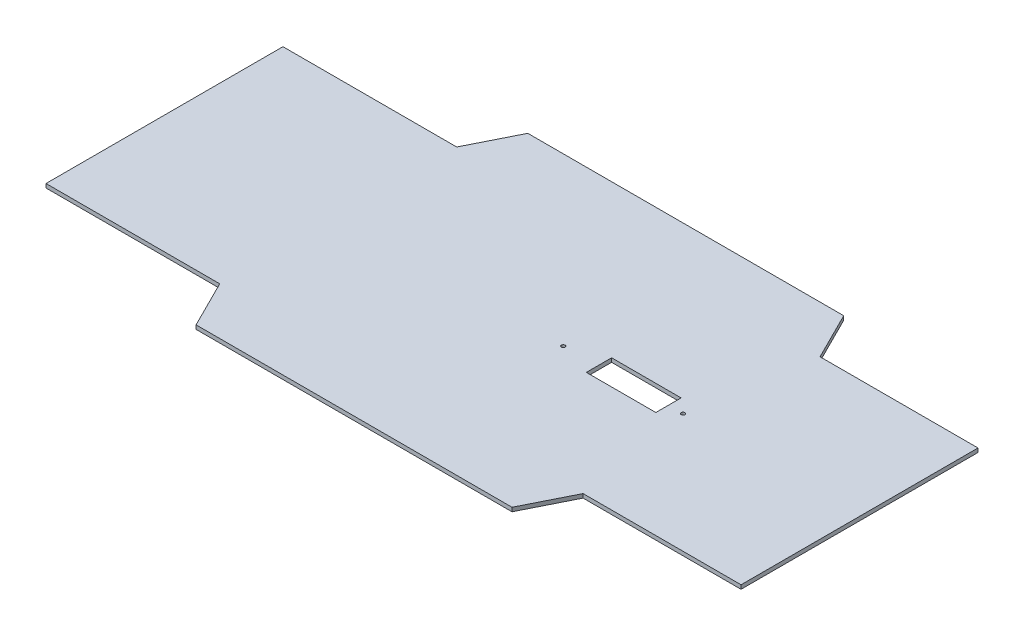
from build123d import *

# Parameters (mm, degrees)
BOSS_EXTRUDE1_DEPTH = 1.5875
SKETCH8_R           = 1.4986
SKETCH8_R_2         = 1.489912236
SKETCH8_W           = 55.88
SKETCH8_H           = 20.32
CUT_EXTRUDE1_DEPTH  = 20.32


with BuildPart() as part:
    # Sketch3 → Boss-Extrude1 (new body, symmetric)
    with BuildSketch(Plane(origin=(0, 0, 0), x_dir=(1, 0, 0), z_dir=(0, 1, 0))):
        Polygon((-279.4, 95.25), (-139.7, 95.25), (-120.65, 133.35), (133.35, 133.35), (152.4, 95.25), (279.4, 95.25), (279.4, -95.25), (152.4, -95.25), (133.35, -133.35), (-120.65, -133.35), (-139.7, -95.25), (-279.4, -95.25), align=None)
    extrude(amount=BOSS_EXTRUDE1_DEPTH, both=True)

    # Sketch8 → Cut-Extrude1 (cut)
    with BuildSketch(Plane(origin=(0, 1.5875, 0), x_dir=(1, 0, 0), z_dir=(0, 1, 0))):
        with Locations((136.914734299, 0.595522161)):
            Circle(SKETCH8_R)
        with Locations((41.78446907, -0.595522161)):
            Circle(SKETCH8_R_2)
        with Locations((97.265334299, 0.595522161)):
            Rectangle(SKETCH8_W, SKETCH8_H)
    extrude(amount=-CUT_EXTRUDE1_DEPTH, mode=Mode.SUBTRACT)


solid = part.part
